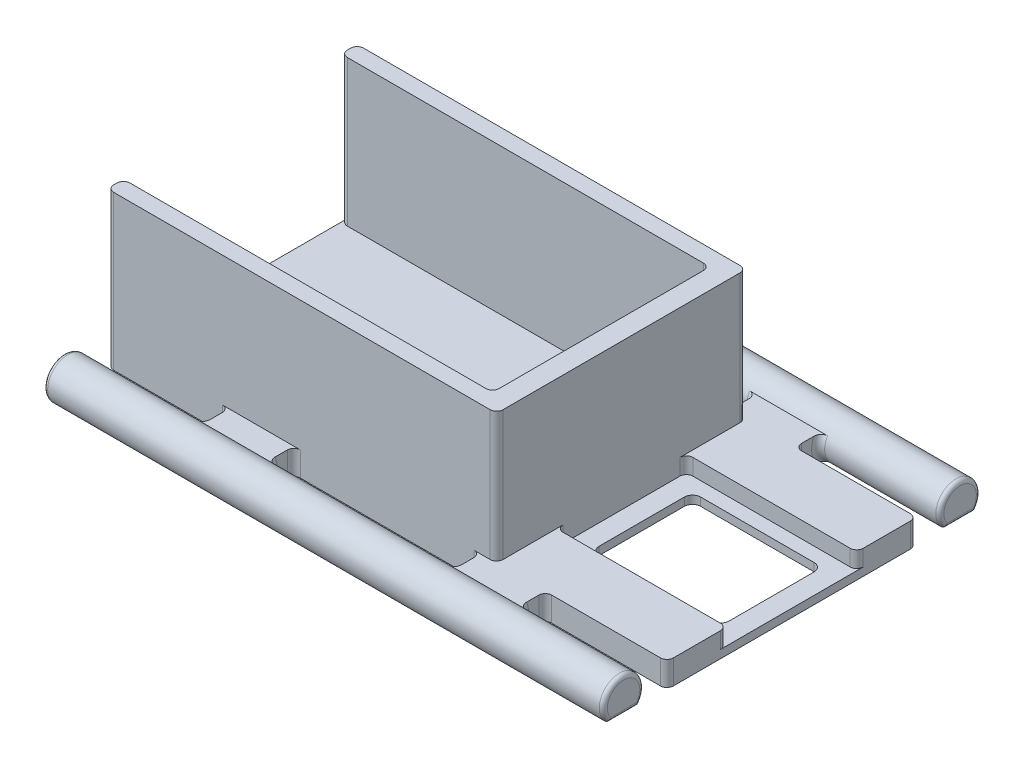
from build123d import *

# Parameters (mm, degrees)
SKETCH1_W             = 69
SKETCH1_H             = 30.800000000000004
BOSS_EXTRUDE1_DEPTH   = 19
CUT_EXTRUDE1_DEPTH    = 45.5
BOSS_EXTRUDE2_DEPTH   = 69
BOSS_EXTRUDE2_2_DEPTH = 69
BOSS_EXTRUDE3_START   = -15
BOSS_EXTRUDE3_DEPTH   = 8
BOSS_EXTRUDE4_START   = -46
BOSS_EXTRUDE4_DEPTH   = 8
CUT_EXTRUDE2_DEPTH    = 18
CUT_EXTRUDE3_DEPTH    = 1
FILLET1_R             = 1
CUT_EXTRUDE4_DEPTH    = 16
FILLET2_R             = 0.8
FILLET3_R             = 0.8
FILLET4_R             = 0.5


with BuildPart() as part:
    # Sketch1 → Boss-Extrude1 (new body)
    with BuildSketch(Plane(origin=(0, 0, 0), x_dir=(1, 0, 0), z_dir=(0, 1, 0))):
        with Locations((2.6528168916095805, 5.837803683949667)):
            Rectangle(SKETCH1_W, SKETCH1_H)
    extrude(amount=BOSS_EXTRUDE1_DEPTH)

    # Sketch2 → Cut-Extrude1 (cut)
    with BuildSketch(Plane.ZY.offset(31.84718310839042)):
        Polygon((-19.237803683949668, 19), (7.562196316050335, 19), (7.562196316050335, 1.0000000000000009), (-19.237803683949664, 1.0000000000000009), align=None)
    extrude(amount=-CUT_EXTRUDE1_DEPTH, mode=Mode.SUBTRACT)



with BuildPart() as body_2:
    # Sketch3 → Boss-Extrude2 (new, through all)
    with BuildSketch(Plane(origin=(37.15281689160958, 0, 0), x_dir=(0, 0, -1), z_dir=(1, 0, 0))):
        with BuildLine():
            ThreePointArc((24.44712422078546, 3.0000000000000018), (24.095143487091267, 1.4492825726759526), (24.74950959320939, -8.9e-16))
            Line((24.74950959320939, 0), (28.415570149174055, 0))
            ThreePointArc((28.415570149174055, 2.2e-16), (28.90983182698023, 0.7869216065845822), (29.08253987119172, 1.6999999999999993))
            ThreePointArc((29.08253987119172, 1.7), (27.25761796814953, 4.107128904526681), (24.44712422078546, 3.0000000000000018))
        make_face()
    extrude(amount=-BOSS_EXTRUDE2_DEPTH)


with BuildPart() as body_3:
    # Sketch3 → Boss-Extrude2 2 (new, through all)
    with BuildSketch(Plane(origin=(37.15281689160958, 0, 0), x_dir=(0, 0, -1), z_dir=(1, 0, 0))):
        with BuildLine():
            ThreePointArc((-12.406932503292389, 1.6999999999999946), (-12.499803598765705, 2.3750780969578003), (-12.771516852886126, 2.999999999999995))
            ThreePointArc((-12.77151685288614, 2.9999999999999867), (-16.414532990279557, 3.694277004740301), (-16.739962781274716, 1.021e-14))
            Line((-16.73996278127473, -3e-16), (-13.073902225310047, -8e-17))
            ThreePointArc((-13.073902225310047, 0), (-12.579640547503875, 0.7869216065845805), (-12.406932503292389, 1.6999999999999946))
        make_face()
    extrude(amount=-BOSS_EXTRUDE2_2_DEPTH)


with BuildPart() as part_1:
    add(part.part)

    add(body_2.part)  # Boss-Extrude3 merges body 2

    add(body_3.part)  # Boss-Extrude3 merges body 3
    # Sketch3_3 → Boss-Extrude3 (add)
    with BuildSketch(Plane(origin=(37.15281689160958, 0, 0), x_dir=(0, 0, -1), z_dir=(1, 0, 0)).offset(BOSS_EXTRUDE3_START)):
        with BuildLine():
            Line((21.237803683949668, 0), (24.74950959320939, 0))
            ThreePointArc((24.74950959320939, -8.9e-16), (24.095143487091267, 1.4492825726759526), (24.44712422078546, 3.0000000000000018))
            Line((24.44712422078546, 3), (21.237803683949668, 3))
            Line((21.237803683949668, 3), (21.237803683949668, 0))
        make_face()
        with BuildLine():
            Line((-9.562196316050334, 0), (-9.562196316050338, 2.999999999999996))
            Line((-9.562196316050338, 2.999999999999996), (-12.771516852886126, 2.999999999999995))
            ThreePointArc((-12.771516852886126, 2.999999999999996), (-12.419536119191934, 1.4492825726759506), (-13.073902225310047, -1.33e-15))
            Line((-13.073902225310047, -8e-17), (-9.562196316050334, 0))
        make_face()
    extrude(amount=-BOSS_EXTRUDE3_DEPTH)

    # Sketch3_5 → Boss-Extrude4 (add)
    with BuildSketch(Plane(origin=(37.15281689160958, 0, 0), x_dir=(0, 0, -1), z_dir=(1, 0, 0)).offset(BOSS_EXTRUDE4_START)):
        with BuildLine():
            Line((21.237803683949668, 0), (24.74950959320939, 0))
            ThreePointArc((24.74950959320939, -8.9e-16), (24.095143487091267, 1.4492825726759526), (24.44712422078546, 3.0000000000000018))
            Line((24.44712422078546, 3), (21.237803683949668, 3))
            Line((21.237803683949668, 3), (21.237803683949668, 0))
        make_face()
        with BuildLine():
            Line((-9.562196316050334, 0), (-9.562196316050338, 2.999999999999996))
            Line((-9.562196316050338, 2.999999999999996), (-12.771516852886126, 2.999999999999995))
            ThreePointArc((-12.771516852886126, 2.999999999999996), (-12.419536119191934, 1.4492825726759506), (-13.073902225310047, -1.33e-15))
            Line((-13.073902225310047, -8e-17), (-9.562196316050334, 0))
        make_face()
    extrude(amount=-BOSS_EXTRUDE4_DEPTH)

    # Sketch4 → Cut-Extrude2 (cut)
    with BuildSketch(Plane(origin=(0, 19, 0), x_dir=(1, 0, 0), z_dir=(0, 1, 0))):
        Polygon((37.15281689160959, 13.837803683949673), (16.15281689160959, 13.837803683949659), (16.152816891609582, -2.1621963160503404), (37.152816891609596, -2.1621963160503386), align=None)
    extrude(amount=-CUT_EXTRUDE2_DEPTH, mode=Mode.SUBTRACT)

    # Sketch5 → Cut-Extrude3 (cut)
    with BuildSketch(Plane(origin=(0, 1, 0), x_dir=(1, 0, 0), z_dir=(0, 1, 0))):
        Polygon((34.65281689160959, 12.087803683949668), (18.652816891609586, 12.087803683949668), (18.652816891609586, -0.4121963160503323), (34.65281689160959, -0.4121963160503333), align=None)
    extrude(amount=-CUT_EXTRUDE3_DEPTH, mode=Mode.SUBTRACT)

    # Fillet1
    fillet1_edges = [part_1.edges().sort_by_distance(p)[0] for p in [
        (34.65281689160959, 0.5, -12.087803683949668),
        (34.65281689160959, 0.5, 0.4121963160503333),
        (18.652816891609586, 0.5, 0.4121963160503323),
        (18.652816891609586, 0.5, -12.087803683949668),
    ]]
    fillet(fillet1_edges, radius=FILLET1_R)

    # Sketch6 → Cut-Extrude4 (cut)
    with BuildSketch(Plane(origin=(0, 19, 0), x_dir=(1, 0, 0), z_dir=(0, 1, 0))):
        Polygon((37.15281689160958, 21.237803683949668), (16.152816891609582, 21.237803683949664), (16.1528168916096, -9.562196316050334), (37.15281689160959, -9.562196316050334), align=None)
    extrude(amount=-CUT_EXTRUDE4_DEPTH, mode=Mode.SUBTRACT)

    # Fillet2
    fillet2_edges = [part_1.edges().sort_by_distance(p)[0] for p in [
        (16.1528168916096, 11, 9.562196316050334),
        (16.152816891609582, 11, -21.237803683949664),
        (13.652816891609579, 10, -19.237803683949664),
        (13.652816891609579, 10, 7.562196316050335),
        (-31.84718310839042, 10, -19.237803683949664),
        (-31.84718310839042, 10, 7.562196316050335),
        (-31.84718310839042, 9.5, -21.237803683949668),
        (-31.84718310839042, 9.5, 9.562196316050334),
    ]]
    fillet(fillet2_edges, radius=FILLET2_R)

    # Fillet3
    fillet3_edges = [part_1.edges().sort_by_distance(p)[0] for p in [
        (16.15281689160959, 2, -13.837803683949659),
        (16.152816891609582, 2, 2.1621963160503404),
        (37.152816891609596, 2, 2.1621963160503386),
        (37.15281689160959, 2, -13.837803683949673),
        (37.15281689160958, 1.5, -21.237803683949668),
        (37.15281689160958, 1.5, 9.562196316050334),
        (22.152816891609582, 1.4492825726759504, 12.419536119191934),
        (22.152816891609582, 1.499999999999998, 9.562196316050336),
        (14.152816891609582, 1.4492825726759504, 12.419536119191934),
        (14.152816891609582, 1.499999999999998, 9.562196316050336),
        (22.152816891609582, 1.4492825726759522, -24.095143487091267),
        (22.152816891609582, 1.5, -21.237803683949668),
        (14.152816891609582, 1.4492825726759522, -24.095143487091267),
        (14.152816891609582, 1.5, -21.237803683949668),
        (-8.847183108390418, 1.4492825726759504, 12.419536119191934),
        (-8.847183108390418, 1.499999999999998, 9.562196316050336),
        (-16.847183108390418, 1.4492825726759504, 12.419536119191934),
        (-16.847183108390418, 1.499999999999998, 9.562196316050336),
        (-8.847183108390418, 1.4492825726759522, -24.095143487091267),
        (-8.847183108390418, 1.5, -21.237803683949668),
        (-16.847183108390418, 1.4492825726759522, -24.095143487091267),
        (-16.847183108390418, 1.5, -21.237803683949668),
    ]]
    fillet(fillet3_edges, radius=FILLET3_R)

    # Fillet4
    fillet4_edges = [part_1.edges().sort_by_distance(p)[0] for p in [
        (37.15281689160958, 4.199999999999978, 14.90693250329239),
        (37.15281689160958, -1.9e-16, 14.906932503292389),
        (-31.847183108390418, 4.199999999999998, 14.906932503292396),
        (-31.847183108390418, -1.9e-16, 14.906932503292389),
        (-31.847183108390418, 4.200000000000031, -26.582539871191685),
        (-31.847183108390418, 0, -26.58253987119172),
        (37.15281689160958, 4.199999999999992, -26.582539871191706),
        (37.15281689160958, 0, -26.58253987119172),
    ]]
    fillet(fillet4_edges, radius=FILLET4_R)


solid = part_1.part
